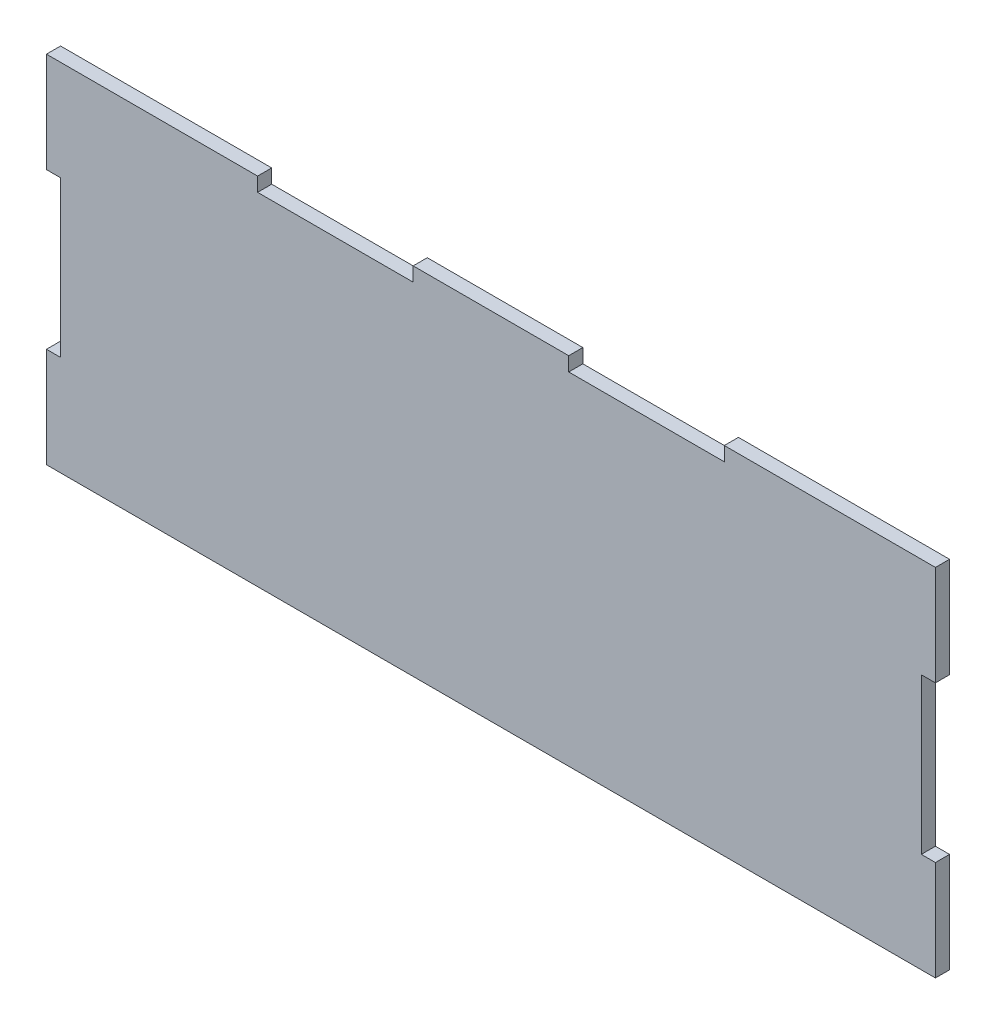
from build123d import *

# Parameters (mm, degrees)
ESQUISSE2_W             = 200
ESQUISSE2_H             = 80
BOSS_EXTRU_1_DEPTH      = 3.175
ESQUISSE3_W             = 35
ESQUISSE3_H             = 3.175
ENL_V_MAT_EXTRU_1_DEPTH = 4.175
ESQUISSE4_W             = 3.175
ESQUISSE4_H             = 35
ENL_V_MAT_EXTRU_2_DEPTH = 4.175


with BuildPart() as part:
    # Esquisse2 → Boss.-Extru.1 (new body)
    with BuildSketch(Plane.XY):
        Rectangle(ESQUISSE2_W, ESQUISSE2_H)
    extrude(amount=BOSS_EXTRU_1_DEPTH)

    # Esquisse3 → Enlèv. mat.-Extru.1 (cut, through all)
    with BuildSketch(Plane.XY.offset(3.175)):
        with Locations((35, 38.4125)):
            Rectangle(ESQUISSE3_W, ESQUISSE3_H)
        with Locations((-35, 38.4125)):
            Rectangle(ESQUISSE3_W, ESQUISSE3_H)
    extrude(amount=-ENL_V_MAT_EXTRU_1_DEPTH, mode=Mode.SUBTRACT)

    # Esquisse4 → Enlèv. mat.-Extru.2 (cut, through all)
    with BuildSketch(Plane.XY.offset(3.175)):
        with Locations((-98.4125, 0)):
            Rectangle(ESQUISSE4_W, ESQUISSE4_H)
    enl_v_mat_extru_2 = extrude(amount=-ENL_V_MAT_EXTRU_2_DEPTH, mode=Mode.SUBTRACT)

    # Symétrie1: Enlèv. mat.-Extru.2 across plane
    add(enl_v_mat_extru_2.mirror(Plane(origin=(0, 0, 0), x_dir=(0, 0, 1), z_dir=(1, 0, 0))), mode=Mode.SUBTRACT)


solid = part.part
